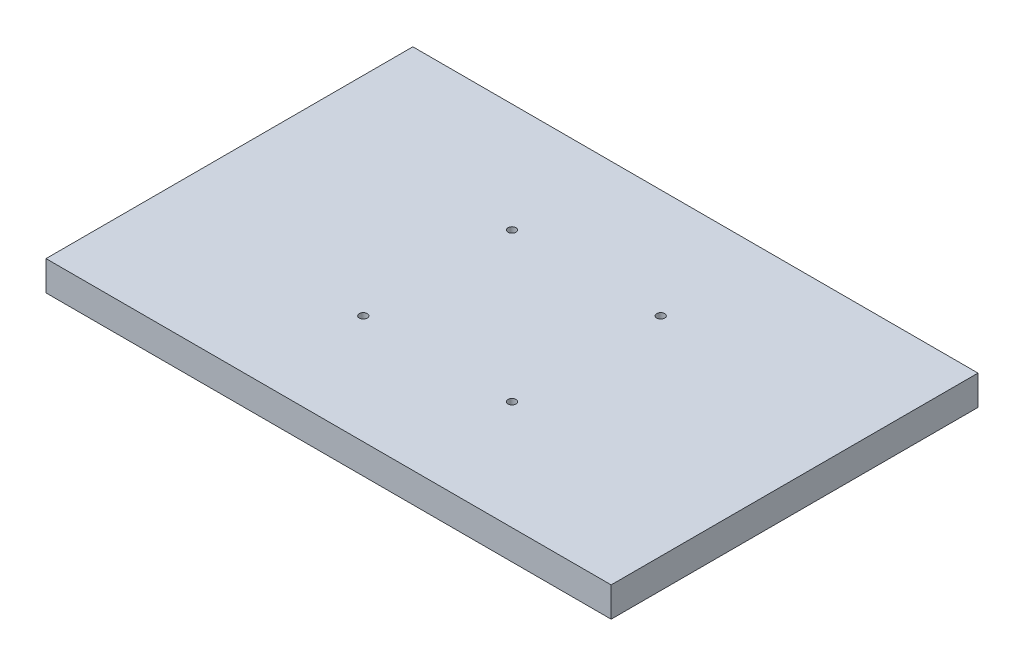
from build123d import *

# Parameters (mm, degrees)
SKETCH_1_W          = 285
SKETCH_1_H          = 185
EXTRUDE_1_DEPTH     = 14
SKETCH_2_R          = 2
CUT_EXTRUDE_1_DEPTH = 8
SKETCH_3_W          = 275
SKETCH_3_H          = 156
EXTRUDE_2_DEPTH     = 1


with BuildPart() as part:
    # 草图1 → 凸台-拉伸1 (new body)
    with BuildSketch(Plane(origin=(0, 0, 0), x_dir=(1, 0, 0), z_dir=(0, 1, 0))):
        Rectangle(SKETCH_1_W, SKETCH_1_H)
    extrude(amount=EXTRUDE_1_DEPTH)

    # 草图2 → 切除-拉伸1 (cut)
    with BuildSketch(Plane(origin=(0, 14, 0), x_dir=(1, 0, 0), z_dir=(0, 1, 0))):
        with Locations((-37.5, 37.5)):
            Circle(SKETCH_2_R)
        with Locations((37.5, 37.5)):
            Circle(SKETCH_2_R)
        with Locations((37.5, -37.5)):
            Circle(SKETCH_2_R)
        with Locations((-37.5, -37.5)):
            Circle(SKETCH_2_R)
    extrude(amount=-CUT_EXTRUDE_1_DEPTH, mode=Mode.SUBTRACT)

    # 草图3 → 凸台-拉伸2 (add)
    with BuildSketch(Plane.XZ):
        Polygon((-142.5, -92.5), (142.5, -92.5), (142.5, -68.5), (142.5, 92.5), (137.5, 92.5), (-137.5, 92.5), (-142.5, 92.5), (-142.5, -68.5), align=None)
        with Locations((0, 9.5)):
            Rectangle(SKETCH_3_W, SKETCH_3_H, mode=Mode.SUBTRACT)
    extrude(amount=EXTRUDE_2_DEPTH)


solid = part.part
